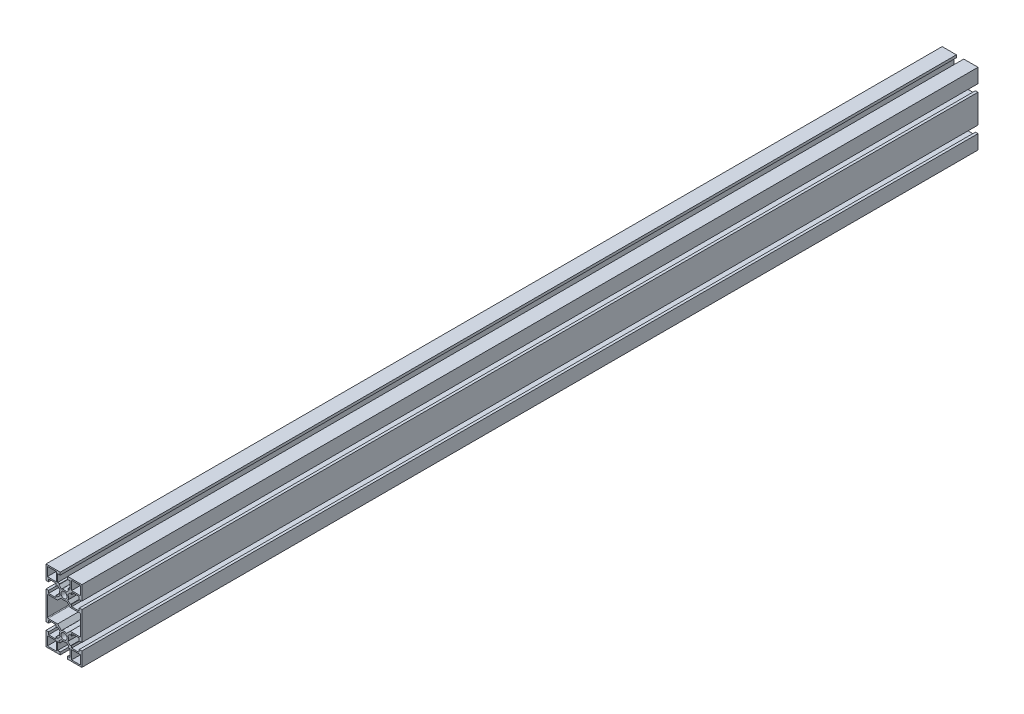
from build123d import *

# Parameters (mm, degrees)
SKETCH_1_R      = 3.4
SKETCH_1_W      = 10
SKETCH_1_H      = 10
EXTRUDE_1_DEPTH = 1000


with BuildPart() as part:
    # Эскиз1 → Бобышка-Вытянуть1 (new body)
    with BuildSketch(Plane.XY):
        with BuildLine():
            Line((-20, 27), (-20, 40))
            Line((-20, 40), (-7, 40))
            Line((-7, 40), (-4.1, 40))
            Line((-4.1, 40), (-4.1, 37.1))
            Line((-4.1, 37.1), (-7, 37.1))
            Line((-7, 37.1), (-7, 28.6))
            Line((-7, 28.6), (-4.582423707, 28.6))
            ThreePointArc((-4.582423707, 28.6), (-4.3976478, 28.476536686), (-4.44100235, 28.258578644))
            Line((-4.44100235, 28.258578644), (-5.571973038, 27.127607956))
            Line((-5.571973038, 27.127607956), (-2.743545913, 24.299180832))
            ThreePointArc((-2.743545913, 24.299180832), (0, 25.1), (2.743545913, 24.299180832))
            Line((2.743545913, 24.299180832), (5.571973038, 27.127607956))
            Line((5.571973038, 27.127607956), (4.44100235, 28.258578644))
            ThreePointArc((4.44100235, 28.258578644), (4.3976478, 28.476536686), (4.582423707, 28.6))
            Line((4.582423707, 28.6), (7, 28.6))
            Line((7, 28.6), (7, 37.1))
            Line((7, 37.1), (4.1, 37.1))
            Line((4.1, 37.1), (4.1, 40))
            Line((4.1, 40), (7, 40))
            Line((7, 40), (20, 40))
            Line((20, 40), (20, 27))
            Line((20, 27), (20, 24.1))
            Line((20, 24.1), (17.1, 24.1))
            Line((17.1, 24.1), (17.1, 27))
            Line((17.1, 27), (8.6, 27))
            Line((8.6, 27), (8.6, 24.582423707))
            ThreePointArc((8.6, 24.582423707), (8.476536686, 24.3976478), (8.258578644, 24.44100235))
            Line((8.258578644, 24.44100235), (7.127607956, 25.571973038))
            Line((7.127607956, 25.571973038), (4.299180832, 22.743545913))
            ThreePointArc((4.299180832, 22.743545913), (5.1, 20), (4.299180832, 17.256454087))
            Line((4.299180832, 17.256454087), (7.127607956, 14.428026962))
            Line((7.127607956, 14.428026962), (8.258578644, 15.55899765))
            ThreePointArc((8.258578644, 15.55899765), (8.476536686, 15.6023522), (8.6, 15.417576293))
            Line((8.6, 15.417576293), (8.6, 13))
            Line((8.6, 13), (17.1, 13))
            Line((17.1, 13), (17.1, 15.9))
            Line((17.1, 15.9), (20, 15.9))
            Line((20, 15.9), (20, 13))
            Line((20, 13), (20, -13))
            Line((20, -13), (20, -15.9))
            Line((20, -15.9), (17.1, -15.9))
            Line((17.1, -15.9), (17.1, -13))
            Line((17.1, -13), (8.6, -13))
            Line((8.6, -13), (8.6, -15.417576293))
            ThreePointArc((8.6, -15.417576293), (8.476536686, -15.6023522), (8.258578644, -15.55899765))
            Line((8.258578644, -15.55899765), (7.127607956, -14.428026962))
            Line((7.127607956, -14.428026962), (4.299180832, -17.256454087))
            ThreePointArc((4.299180832, -17.256454087), (5.1, -20), (4.299180832, -22.743545913))
            Line((4.299180832, -22.743545913), (7.127607956, -25.571973038))
            Line((7.127607956, -25.571973038), (8.258578644, -24.44100235))
            ThreePointArc((8.258578644, -24.44100235), (8.476536686, -24.3976478), (8.6, -24.582423707))
            Line((8.6, -24.582423707), (8.6, -27))
            Line((8.6, -27), (17.1, -27))
            Line((17.1, -27), (17.1, -24.1))
            Line((17.1, -24.1), (20, -24.1))
            Line((20, -24.1), (20, -27))
            Line((20, -27), (20, -40))
            Line((20, -40), (7, -40))
            Line((7, -40), (4.1, -40))
            Line((4.1, -40), (4.1, -37.1))
            Line((4.1, -37.1), (7, -37.1))
            Line((7, -37.1), (7, -28.6))
            Line((7, -28.6), (4.582423707, -28.6))
            ThreePointArc((4.582423707, -28.6), (4.3976478, -28.476536686), (4.44100235, -28.258578644))
            Line((4.44100235, -28.258578644), (5.571973038, -27.127607956))
            Line((5.571973038, -27.127607956), (2.743545913, -24.299180832))
            ThreePointArc((2.743545913, -24.299180832), (0, -25.1), (-2.743545913, -24.299180832))
            Line((-2.743545913, -24.299180832), (-5.571973038, -27.127607956))
            Line((-5.571973038, -27.127607956), (-4.44100235, -28.258578644))
            ThreePointArc((-4.44100235, -28.258578644), (-4.3976478, -28.476536686), (-4.582423707, -28.6))
            Line((-4.582423707, -28.6), (-7, -28.6))
            Line((-7, -28.6), (-7, -37.1))
            Line((-7, -37.1), (-4.1, -37.1))
            Line((-4.1, -37.1), (-4.1, -40))
            Line((-4.1, -40), (-7, -40))
            Line((-7, -40), (-20, -40))
            Line((-20, -40), (-20, -27))
            Line((-20, -27), (-20, -24.1))
            Line((-20, -24.1), (-17.1, -24.1))
            Line((-17.1, -24.1), (-17.1, -27))
            Line((-17.1, -27), (-8.6, -27))
            Line((-8.6, -27), (-8.6, -24.582423707))
            ThreePointArc((-8.6, -24.582423707), (-8.476536686, -24.3976478), (-8.258578644, -24.44100235))
            Line((-8.258578644, -24.44100235), (-7.127607956, -25.571973038))
            Line((-7.127607956, -25.571973038), (-4.299180832, -22.743545913))
            ThreePointArc((-4.299180832, -22.743545913), (-5.1, -20), (-4.299180832, -17.256454087))
            Line((-4.299180832, -17.256454087), (-7.127607956, -14.428026962))
            Line((-7.127607956, -14.428026962), (-8.258578644, -15.55899765))
            ThreePointArc((-8.258578644, -15.55899765), (-8.476536686, -15.6023522), (-8.6, -15.417576293))
            Line((-8.6, -15.417576293), (-8.6, -13))
            Line((-8.6, -13), (-17.1, -13))
            Line((-17.1, -13), (-17.1, -15.9))
            Line((-17.1, -15.9), (-20, -15.9))
            Line((-20, -15.9), (-20, -13))
            Line((-20, -13), (-20, 13))
            Line((-20, 13), (-20, 15.9))
            Line((-20, 15.9), (-17.1, 15.9))
            Line((-17.1, 15.9), (-17.1, 13))
            Line((-17.1, 13), (-8.6, 13))
            Line((-8.6, 13), (-8.6, 15.417576293))
            ThreePointArc((-8.6, 15.417576293), (-8.476536686, 15.6023522), (-8.258578644, 15.55899765))
            Line((-8.258578644, 15.55899765), (-7.127607956, 14.428026962))
            Line((-7.127607956, 14.428026962), (-4.299180832, 17.256454087))
            ThreePointArc((-4.299180832, 17.256454087), (-5.1, 20), (-4.299180832, 22.743545913))
            Line((-4.299180832, 22.743545913), (-7.127607956, 25.571973038))
            Line((-7.127607956, 25.571973038), (-8.258578644, 24.44100235))
            ThreePointArc((-8.258578644, 24.44100235), (-8.476536686, 24.3976478), (-8.6, 24.582423707))
            Line((-8.6, 24.582423707), (-8.6, 27))
            Line((-8.6, 27), (-17.1, 27))
            Line((-17.1, 27), (-17.1, 24.1))
            Line((-17.1, 24.1), (-20, 24.1))
            Line((-20, 24.1), (-20, 27))
        make_face()
        with Locations((0, 20)):
            Circle(SKETCH_1_R, mode=Mode.SUBTRACT)
        with Locations((0, -20)):
            Circle(SKETCH_1_R, mode=Mode.SUBTRACT)
        with Locations((13.5, 33.5)):
            Rectangle(SKETCH_1_W, SKETCH_1_H, mode=Mode.SUBTRACT)
        with Locations((-13.5, 33.5)):
            Rectangle(SKETCH_1_W, SKETCH_1_H, mode=Mode.SUBTRACT)
        with Locations((13.5, -33.5)):
            Rectangle(SKETCH_1_W, SKETCH_1_H, mode=Mode.SUBTRACT)
        with Locations((-13.5, -33.5)):
            Rectangle(SKETCH_1_W, SKETCH_1_H, mode=Mode.SUBTRACT)
        with BuildLine():
            Line((-17.7, 11.5), (-7.085786438, 11.5))
            Line((-7.085786438, 11.5), (-2.829134161, 15.756652277))
            ThreePointArc((-2.829134161, 15.756652277), (0, 14.9), (2.829134161, 15.756652277))
            Line((2.829134161, 15.756652277), (7.085786438, 11.5))
            Line((7.085786438, 11.5), (17.7, 11.5))
            ThreePointArc((17.7, 11.5), (18.265685425, 11.265685425), (18.5, 10.7))
            Line((18.5, 10.7), (18.5, -10.7))
            ThreePointArc((18.5, -10.7), (18.265685425, -11.265685425), (17.7, -11.5))
            Line((17.7, -11.5), (7.085786438, -11.5))
            Line((7.085786438, -11.5), (2.829134161, -15.756652277))
            ThreePointArc((2.829134161, -15.756652277), (0, -14.9), (-2.829134161, -15.756652277))
            Line((-2.829134161, -15.756652277), (-7.085786438, -11.5))
            Line((-7.085786438, -11.5), (-17.7, -11.5))
            ThreePointArc((-17.7, -11.5), (-18.265685425, -11.265685425), (-18.5, -10.7))
            Line((-18.5, -10.7), (-18.5, 10.7))
            ThreePointArc((-18.5, 10.7), (-18.265685425, 11.265685425), (-17.7, 11.5))
        make_face(mode=Mode.SUBTRACT)
    extrude(amount=EXTRUDE_1_DEPTH)


solid = part.part
